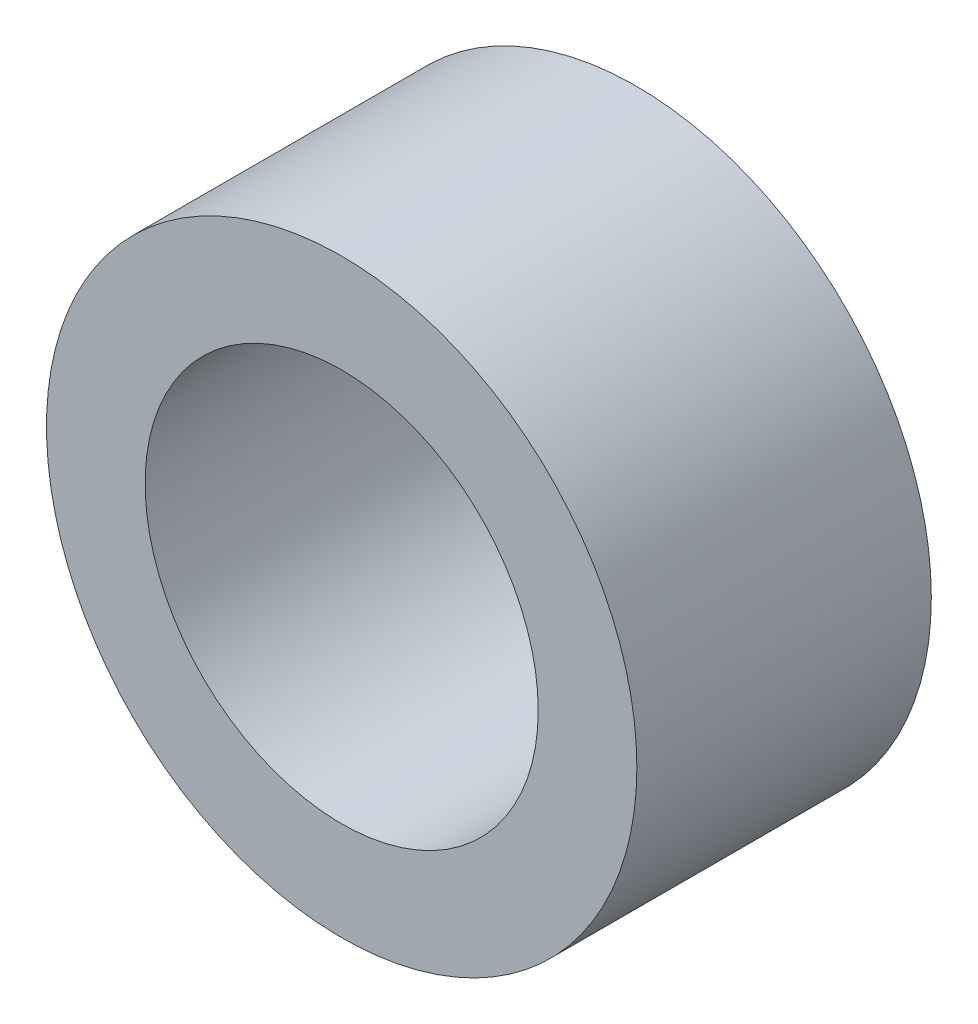
from build123d import *

# Parameters (mm, degrees)
SKETCH1_R      = 6.015
SKETCH1_R_2    = 4.005
EXTRUDE1_DEPTH = 3


with BuildPart() as part:
    # Sketch1 → Extrude1 (new body, symmetric)
    with BuildSketch(Plane.XY):
        Circle(SKETCH1_R)
        Circle(SKETCH1_R_2, mode=Mode.SUBTRACT)
    extrude(amount=EXTRUDE1_DEPTH, both=True)


solid = part.part
